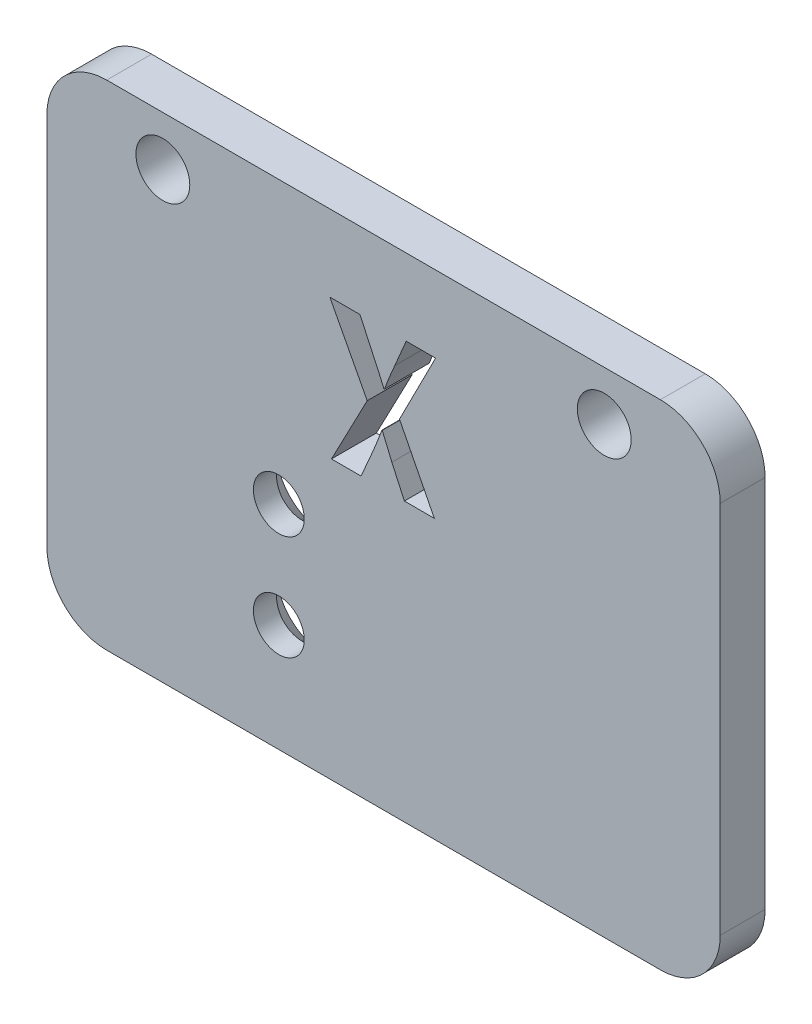
from build123d import *

# Parameters (mm, degrees)
SKETCH1_R                                    = 1.8
BOSS_EXTRUDE1_DEPTH                          = 3
FILLET1_R                                    = 4
CSK_FOR_M3_COUNTERSUNK_FLAT_HEAD_SCR_2_COUNT = 2
CSK_FOR_M3_COUNTERSUNK_FLAT_HEAD_SCR_2_PITCH = 7


with BuildPart() as part:
    # Sketch1 → Boss-Extrude1 (new body)
    with BuildSketch(Plane.XY):
        Polygon((22.5, 19.3), (-22.5, 19.3), (-22.5, -9.7), (-22.5, -13.7), (22.5, -13.7), (22.5, -9.7), align=None)
        with Locations((14.75, 16)):
            Circle(SKETCH1_R, mode=Mode.SUBTRACT)
        with Locations((-14.75, 16)):
            Circle(SKETCH1_R, mode=Mode.SUBTRACT)
        with BuildLine():
            Line((-3.479994944, 4.879643035), (-1.504454613, 4.879643035))
            Line((-1.504454613, 4.879643035), (-0.716662457, 6.696078227))
            add(Edge.make_bspline(
                [(-0.716662457, 6.696078227), (-0.662988728, 6.823847603), (-0.558253832, 7.073167199), (-0.407159323, 7.448475347), (-0.260246479, 7.833509844), (-0.163053085, 8.096372908), (-0.1123781, 8.233425246)],
                knots=[0, 0, 0, 0, 0.000415753, 0.000811269, 0.001213674, 0.001652036, 0.001652036, 0.001652036, 0.001652036], degree=3))
            Line((-0.1123781, 8.233425246), (-0.086428732, 8.234214033))
            add(Edge.make_bspline(
                [(-0.086428732, 8.234214033), (0.016216114, 7.980645356), (0.223344012, 7.468966992), (0.443707362, 6.962847127), (0.554866869, 6.707541356)],
                knots=[0, 0, 0, 0, 0.000820631, 0.001655958, 0.001655958, 0.001655958, 0.001655958], degree=3))
            Line((0.554866869, 6.707541356), (1.392196546, 4.879643035))
            Line((1.392196546, 4.879643035), (3.391976635, 4.879643035))
            Line((3.391976635, 4.879643035), (1.064959804, 9.457455895))
            Line((1.064959804, 9.457455895), (3.476699187, 14.192976369))
            Line((3.476699187, 14.192976369), (1.513395339, 14.192976369))
            Line((1.513395339, 14.192976369), (0.749842942, 12.400503146))
            add(Edge.make_bspline(
                [(0.749842942, 12.400503146), (0.683388417, 12.247174796), (0.555592527, 11.952315518), (0.374121285, 11.520725487), (0.206338492, 11.105720206), (0.107367824, 10.829588001), (0.057944958, 10.691696187)],
                knots=[0, 0, 0, 0, 0.000501324, 0.000964075, 0.001404587, 0.001843989, 0.001843989, 0.001843989, 0.001843989], degree=3))
            Line((0.057944958, 10.691696187), (0.022650182, 10.692809062))
            add(Edge.make_bspline(
                [(0.022650182, 10.692809062), (-0.035080758, 10.828878889), (-0.150655612, 11.101284822), (-0.329423009, 11.514746078), (-0.526398165, 11.943735097), (-0.667307197, 12.235388249), (-0.740993098, 12.387903135)],
                knots=[0, 0, 0, 0, 0.000443432, 0.000887733, 0.001351306, 0.001859446, 0.001859446, 0.001859446, 0.001859446], degree=3))
            Line((-0.740993098, 12.387903135), (-1.577173889, 14.192976369))
            Line((-1.577173889, 14.192976369), (-3.589073858, 14.192976369))
            Line((-3.589073858, 14.192976369), (-1.092378716, 9.445344589))
            Line((-1.092378716, 9.445344589), (-3.479994944, 4.879643035))
        make_face(mode=Mode.SUBTRACT)
    extrude(amount=BOSS_EXTRUDE1_DEPTH)

    # Fillet1
    fillet1_edges = [part.edges().sort_by_distance(p)[0] for p in [
        (-22.5, 19.3, 1.5),
        (22.5, 19.3, 1.5),
        (22.5, -13.7, 1.5),
        (-22.5, -13.7, 1.5),
    ]]
    fillet(fillet1_edges, radius=FILLET1_R)

    # Sketch6 → CSK for M3 Countersunk Flat Head Screw1 (revolve, cut)
    with BuildSketch(Plane(origin=(-7, -6.5, 0), x_dir=(0, 1, 0), z_dir=(1, 0, 0))):
        Polygon((0, 0), (0, 3), (1.7, 3), (1.7, 1.45), (3.15, 0), align=None)
    csk_for_m3_countersunk_flat_head_screw1 = revolve(axis=Axis((-7, -6.5, -6.35), (0, 0, 1)), mode=Mode.SUBTRACT)

    # CSK for M3 Countersunk Flat Head Scr 2: CSK for M3 Countersunk Flat Head Screw1 ×2
    with Locations(*[(0, i * CSK_FOR_M3_COUNTERSUNK_FLAT_HEAD_SCR_2_PITCH, 0) for i in range(1, CSK_FOR_M3_COUNTERSUNK_FLAT_HEAD_SCR_2_COUNT)]):
        add(csk_for_m3_countersunk_flat_head_screw1, mode=Mode.SUBTRACT)


solid = part.part
